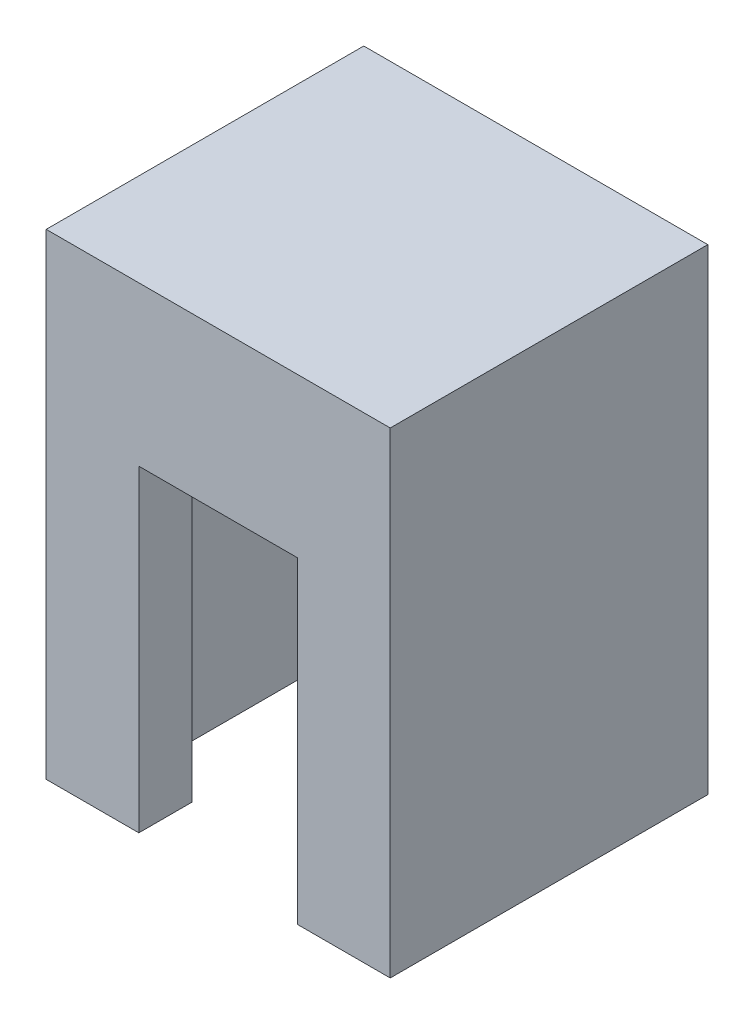
from build123d import *

# Parameters (mm, degrees)
ESQUISSE1_W             = 13
ESQUISSE1_H             = 18
BOSS_EXTRU_1_DEPTH      = 12
ENL_V_MAT_EXTRU_1_DEPTH = 12


with BuildPart() as part:
    # Esquisse1 → Boss.-Extru.1 (new body)
    with BuildSketch(Plane.XY):
        Rectangle(ESQUISSE1_W, ESQUISSE1_H)
    extrude(amount=BOSS_EXTRU_1_DEPTH)

    # Esquisse2 → Enlèv. mat.-Extru.1 (cut)
    with BuildSketch(Plane.XZ.offset(9)):
        Polygon((-5, 10), (-3, 10), (-3, 12), (3, 12), (3, 10), (5, 10), (5, 2), (3, 2), (3, 0), (-3, 0), (-3, 2), (-5, 2), align=None)
    extrude(amount=-ENL_V_MAT_EXTRU_1_DEPTH, mode=Mode.SUBTRACT)


solid = part.part
